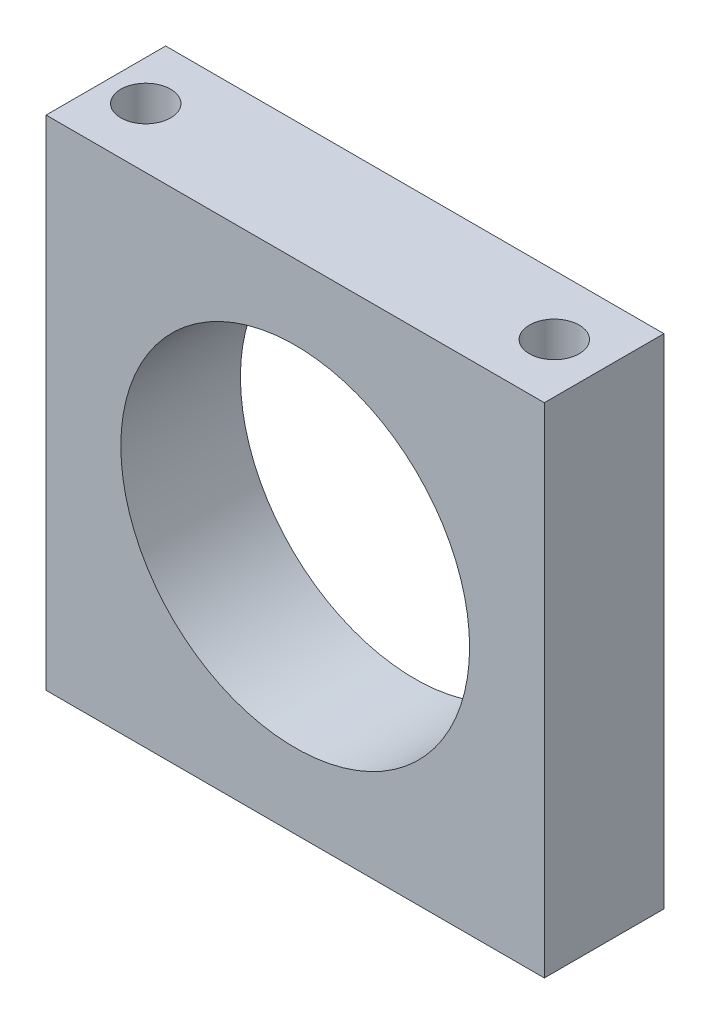
from build123d import *

# Parameters (mm, degrees)
SCHIZZO1_W                   = 50
SCHIZZO1_H                   = 50
SCHIZZO1_R                   = 17.5
ESTRUSIONE_ESTRUSIONE1_DEPTH = 12
SCHIZZO2_R                   = 2.5
TAGLIO_ESTRUSIONE1_DEPTH     = 5
SCHIZZO3_R                   = 2.5
TAGLIO_ESTRUSIONE2_DEPTH     = 5


with BuildPart() as part:
    # Schizzo1 → Estrusione-Estrusione1 (new body)
    with BuildSketch(Plane.XY):
        Rectangle(SCHIZZO1_W, SCHIZZO1_H)
        Circle(SCHIZZO1_R, mode=Mode.SUBTRACT)
    extrude(amount=ESTRUSIONE_ESTRUSIONE1_DEPTH)

    # Schizzo2 → Taglio-Estrusione1 (cut)
    with BuildSketch(Plane(origin=(0, -25, 0), x_dir=(-1, 0, 0), z_dir=(0, -1, 0))):
        with Locations((21, -6)):
            Circle(SCHIZZO2_R)
        with Locations((-20, -6)):
            Circle(SCHIZZO2_R)
    extrude(amount=-TAGLIO_ESTRUSIONE1_DEPTH, mode=Mode.SUBTRACT)

    # Schizzo3 → Taglio-Estrusione2 (cut)
    with BuildSketch(Plane(origin=(0, 25, 0), x_dir=(1, 0, 0), z_dir=(0, 1, 0))):
        with Locations((20, -6)):
            Circle(SCHIZZO3_R)
        with Locations((-21, -6)):
            Circle(SCHIZZO3_R)
    extrude(amount=-TAGLIO_ESTRUSIONE2_DEPTH, mode=Mode.SUBTRACT)


solid = part.part
